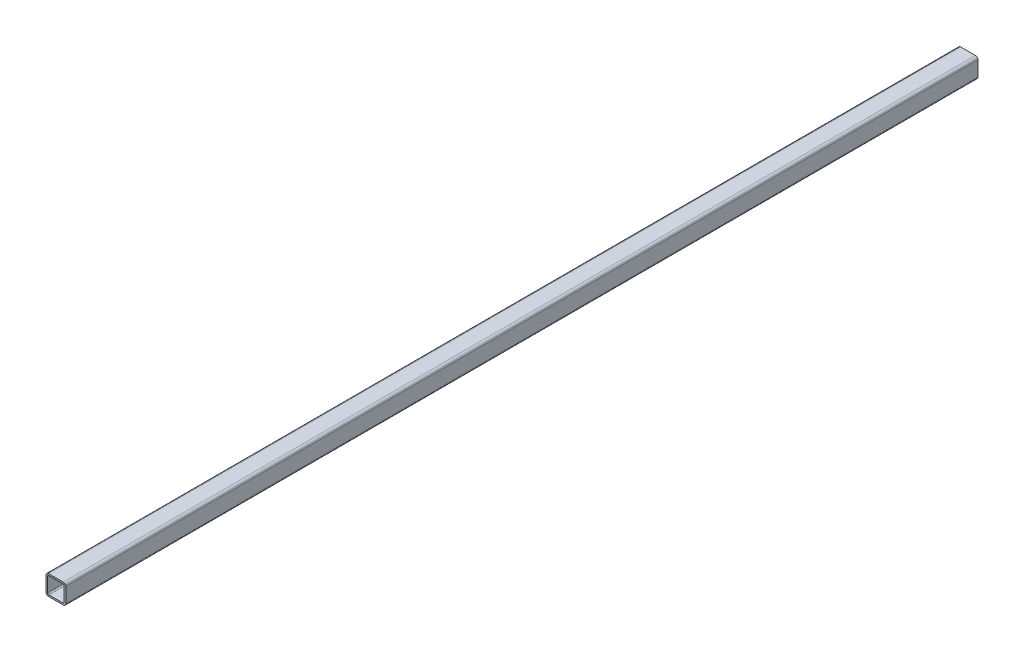
from build123d import *

# Parameters (mm, degrees)
SKETCH3_W                = 25.4
SKETCH3_H                = 25.4
SKETCH3_W_2              = 21.336
SKETCH3_H_2              = 21.336
BOSS_EXTRUDE1_DEPTH      = 609.6
BOSS_EXTRUDE1_DEPTH_BACK = 609.6
FILLET1_R                = 3.175
FILLET2_R                = 1.5875
SKETCH4_W                = 25.4
SKETCH4_H                = 50.8
CUT_EXTRUDE1_DEPTH       = 26.4


with BuildPart() as part:
    # Sketch3 → Boss-Extrude1 (new body, two sides)
    with BuildSketch(Plane.XY) as boss_extrude1_sk:
        Rectangle(SKETCH3_W, SKETCH3_H)
        Rectangle(SKETCH3_W_2, SKETCH3_H_2, mode=Mode.SUBTRACT)
    extrude(amount=BOSS_EXTRUDE1_DEPTH)
    extrude(boss_extrude1_sk.sketch, amount=-BOSS_EXTRUDE1_DEPTH_BACK)

    # Fillet1
    fillet1_edges = [part.edges().sort_by_distance(p)[0] for p in [
        (12.7, -12.7, 0),
        (-12.7, -12.7, 0),
        (-12.7, 12.7, 0),
        (12.7, 12.7, 0),
    ]]
    fillet(fillet1_edges, radius=FILLET1_R)

    # Fillet2
    fillet2_edges = [part.edges().sort_by_distance(p)[0] for p in [
        (10.668, -10.668, 0),
        (10.668, 10.668, 0),
        (-10.668, 10.668, 0),
        (-10.668, -10.668, 0),
    ]]
    fillet(fillet2_edges, radius=FILLET2_R)

    # Sketch4 → Cut-Extrude1 (cut, through all)
    with BuildSketch(Plane(origin=(0, 12.7, 0), x_dir=(1, 0, 0), z_dir=(0, 1, 0))):
        with Locations((0, 584.2)):
            Rectangle(SKETCH4_W, SKETCH4_H)
    extrude(amount=-CUT_EXTRUDE1_DEPTH, mode=Mode.SUBTRACT)


solid = part.part
